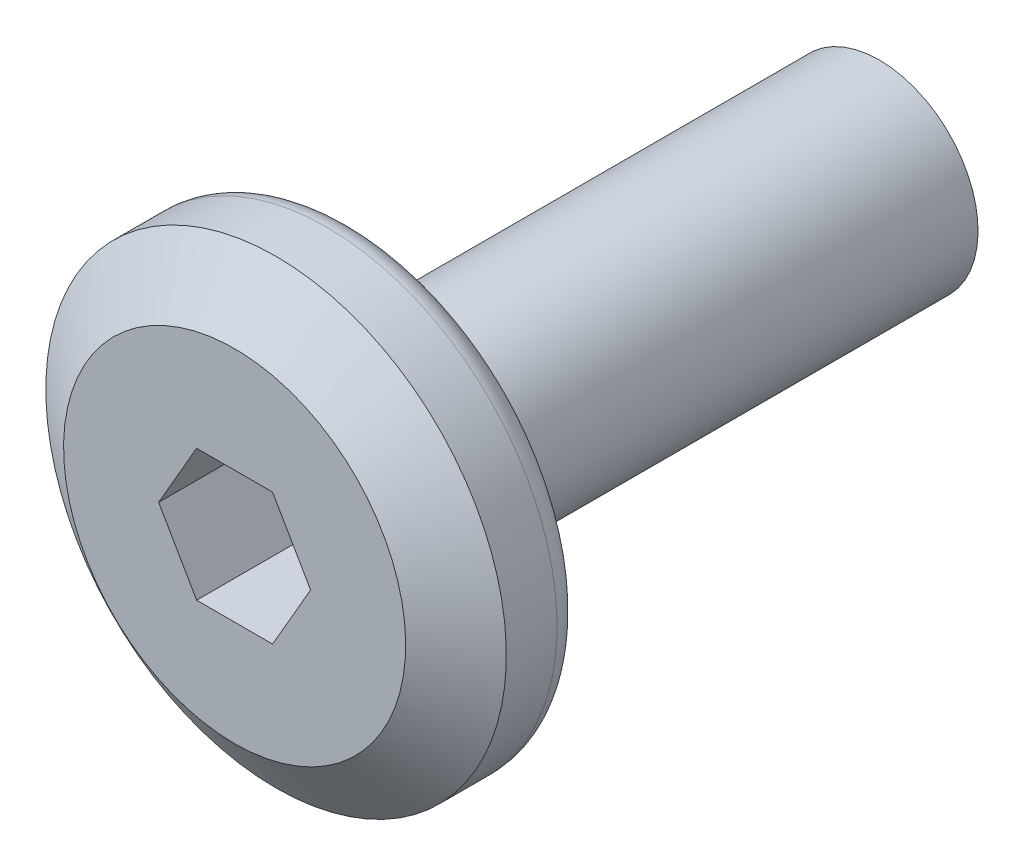
from build123d import *

# Parameters (mm, degrees)
CHAMFER_1_SIZE      = 0.9
CHAMFER_1_SIZE2     = 0.630186784
CUT_EXTRUDE_1_DEPTH = 1.5
FILLET_1_R          = 0.4


with BuildPart() as part:
    # 草图2 → 旋转1 (revolve)
    with BuildSketch(Plane(origin=(0, 0, 0), x_dir=(0, 0, -1), z_dir=(1, 0, 0))):
        Polygon((0, 0), (0, 3.5), (1.8, 3.5), (1.8, 1.5), (9.8, 1.5), (9.8, 0), align=None)
    revolve(axis=Axis((0, 0, -9.8), (0, 0, 1)))

    # 倒角1
    chamfer_1_edges = [part.edges().sort_by_distance(p)[0] for p in [
        (0, -3.5, 0),
    ]]
    chamfer_1_side = [part.faces().sort_by_distance(p)[0] for p in [
        (0, 0, 0),
    ]]
    chamfer(chamfer_1_edges, length=CHAMFER_1_SIZE, length2=CHAMFER_1_SIZE2, reference=chamfer_1_side[0])

    # 草图3 → 切除-拉伸1 (cut)
    with BuildSketch(Plane.XY):
        Polygon((0.577350269, 1), (-0.577350269, 1), (-1.154700538, 0), (-0.577350269, -1), (0.577350269, -1), (1.154700538, 0), align=None)
    extrude(amount=-CUT_EXTRUDE_1_DEPTH, mode=Mode.SUBTRACT)

    # 圆角1
    fillet_1_edges = [part.edges().sort_by_distance(p)[0] for p in [
        (0, -3.5, -1.8),
    ]]
    fillet(fillet_1_edges, radius=FILLET_1_R)


solid = part.part
